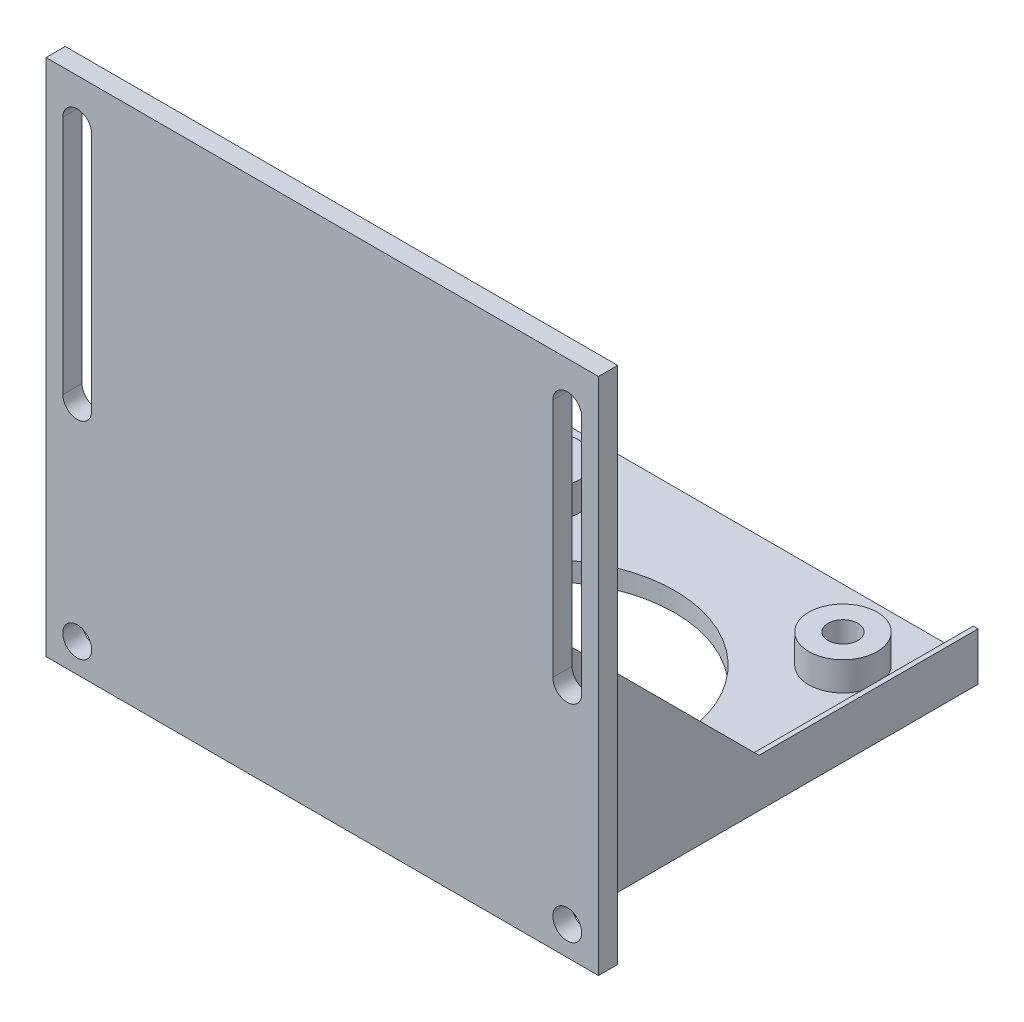
from build123d import *

# Parameters (mm, degrees)
SKETCH3_W                = 44.5
SKETCH3_H                = 44
SKETCH3_R                = 13.462
SKETCH3_R_2              = 1.554126588
FRONT_FACE_DEPTH         = 5
SKETCH4_W                = 44.5
SKETCH4_H                = 54
BOTTOM_PLATE_DEPTH       = 2
RIB_DEPTH                = 0.5
SKETCH6_W                = 6.5
SKETCH6_H                = 54
SKETCH6_R                = 1.5
BOTTOM_SCREW_HOLES_DEPTH = 2
SKETCH7_W                = 43.5
SKETCH7_H                = 3
CUT_EXTRUDE1_DEPTH       = 44
SKETCH8_R                = 3.554126588
SKETCH8_R_2              = 1.554126588
BOSS_EXTRUDE5_DEPTH      = 3


with BuildPart() as part:
    # Sketch3 → Front Face (new body)
    with BuildSketch(Plane.XZ):
        with Locations((0, -22)):
            Rectangle(SKETCH3_W, SKETCH3_H)
        with Locations((0, -21.209)):
            Circle(SKETCH3_R, mode=Mode.SUBTRACT)
        with Locations((15.494, -5.715)):
            Circle(SKETCH3_R_2, mode=Mode.SUBTRACT)
        with Locations((-15.494, -5.715)):
            Circle(SKETCH3_R_2, mode=Mode.SUBTRACT)
        with Locations((-15.494, -36.703)):
            Circle(SKETCH3_R_2, mode=Mode.SUBTRACT)
        with Locations((15.494, -36.703)):
            Circle(SKETCH3_R_2, mode=Mode.SUBTRACT)
    front_face = extrude(amount=FRONT_FACE_DEPTH)

    # Sketch4 → Bottom Plate (add)
    with BuildSketch(Plane.XY):
        with Locations((0, 22)):
            Rectangle(SKETCH4_W, SKETCH4_H)
    bottom_plate = extrude(amount=BOTTOM_PLATE_DEPTH)

    # Sketch5 → Rib (add)
    with BuildSketch(Plane.ZY.offset(22.25)):
        Polygon((-21.209, 0), (0, 21.209), (0, 0), align=None)
    rib = extrude(amount=-RIB_DEPTH)

    # Sketch6 → Bottom Screw Holes (add)
    with BuildSketch(Plane(origin=(21.209, 47.45, 0), x_dir=(-1, 0, 0), z_dir=(0, 0, -1))):
        with Locations((46.709, -25.45)):
            Rectangle(SKETCH6_W, SKETCH6_H)
        with Locations((46.709, -49.45)):
            Circle(SKETCH6_R, mode=Mode.SUBTRACT)
        with BuildLine():
            Line((48.209, -2.95), (48.209, -27.95))
            ThreePointArc((48.209, -27.95), (46.709, -29.45), (45.209, -27.95))
            Line((45.209, -27.95), (45.209, -2.95))
            ThreePointArc((45.209, -2.95), (46.709, -1.45), (48.209, -2.95))
        make_face(mode=Mode.SUBTRACT)
    bottom_screw_holes = extrude(amount=-BOTTOM_SCREW_HOLES_DEPTH)

    # Mirror of Rib and Bottom Screws: Front Face, Bottom Plate, Rib, Bottom Screw Holes across plane
    add(front_face.mirror(Plane.ZY))
    add(bottom_plate.mirror(Plane.ZY))
    add(rib.mirror(Plane.ZY))
    add(bottom_screw_holes.mirror(Plane.ZY))

    # Sketch7 → Cut-Extrude1 (cut)
    with BuildSketch(Plane(origin=(0, 0, -44), x_dir=(-1, 0, 0), z_dir=(0, 0, -1))):
        with Locations((0, -1.5)):
            Rectangle(SKETCH7_W, SKETCH7_H)
    extrude(amount=-CUT_EXTRUDE1_DEPTH, mode=Mode.SUBTRACT)

    # Sketch8 → Boss-Extrude5 (add)
    with BuildSketch(Plane(origin=(0, -3, 0), x_dir=(1, 0, 0), z_dir=(0, 1, 0))):
        with Locations((-15.494, 36.703)):
            Circle(SKETCH8_R)
        with Locations((-15.494, 36.703)):
            Circle(SKETCH8_R_2, mode=Mode.SUBTRACT)
        with Locations((15.494, 36.703)):
            Circle(SKETCH8_R)
        with Locations((15.494, 36.703)):
            Circle(SKETCH8_R_2, mode=Mode.SUBTRACT)
        with Locations((15.494, 5.715)):
            Circle(SKETCH8_R)
        with Locations((15.494, 5.715)):
            Circle(SKETCH8_R_2, mode=Mode.SUBTRACT)
        with Locations((-15.494, 5.715)):
            Circle(SKETCH8_R)
        with Locations((-15.494, 5.715)):
            Circle(SKETCH8_R_2, mode=Mode.SUBTRACT)
    extrude(amount=BOSS_EXTRUDE5_DEPTH)


solid = part.part
